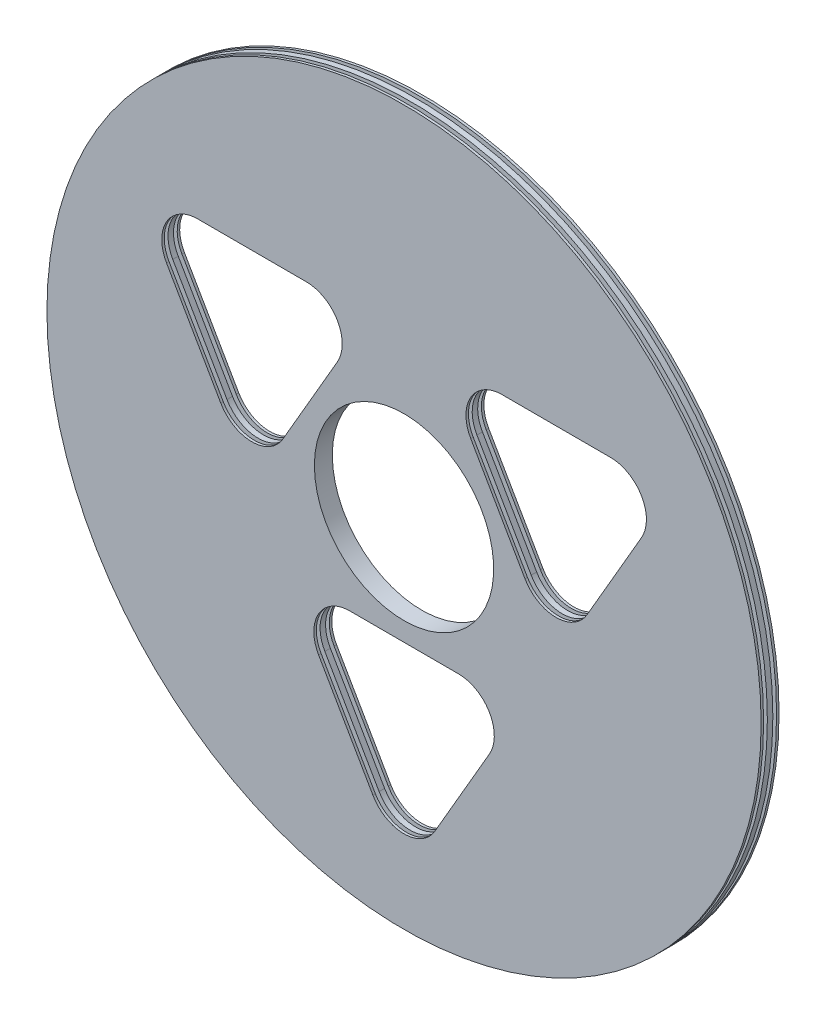
from build123d import *

# Parameters (mm, degrees)
SKETCH_1_R          = 199.1381229
EXTRUDE_1_DEPTH     = 10
SKETCH_2_R          = 50
CUT_EXTRUDE_1_DEPTH = 10
SKETCH_4_W          = 2.080900767
SKETCH_4_H          = 145.70816296


with BuildPart() as part:
    # Эскиз1 → Бобышка-Вытянуть1 (new body)
    with BuildSketch(Plane.XY):
        Circle(SKETCH_1_R)
    extrude(amount=EXTRUDE_1_DEPTH)

    # Эскиз2 → Вырез-Вытянуть1 (cut)
    with BuildSketch(Plane(origin=(0, 0, 0), x_dir=(-1, 0, 0), z_dir=(0, 0, -1))):
        Circle(SKETCH_2_R)
        with BuildLine():
            Line((-132.460540699, 56.403298942), (-102.076076874, 3.945846105))
            ThreePointArc((-102.076076874, 3.945846105), (-84.74156592, -6.029860886), (-67.435094768, 3.994412468))
            Line((-67.435094768, 3.994412468), (-37.197839906, 56.536856438))
            ThreePointArc((-37.197839906, 56.536856438), (-37.225879708, 76.536836783), (-54.560390663, 86.512543774))
            Line((-54.560390663, 86.512543774), (-115.182109349, 86.427552639))
            ThreePointArc((-115.182109349, 86.427552639), (-132.488580502, 76.403279286), (-132.460540699, 56.403298942))
        make_face()
        with BuildLine():
            Line((17.383580609, -142.915842715), (47.620835471, -90.373398744))
            ThreePointArc((47.620835471, -90.373398744), (47.592795668, -70.3734184), (30.258284714, -60.397711409))
            Line((30.258284714, -60.397711409), (-30.363433973, -60.482702544))
            ThreePointArc((-30.363433973, -60.482702544), (-47.669905125, -70.506975897), (-47.641865322, -90.506956241))
            Line((-47.641865322, -90.506956241), (-17.257401498, -142.964409078))
            ThreePointArc((-17.257401498, -142.964409078), (0.077109457, -152.940116069), (17.383580609, -142.915842715))
        make_face()
        with BuildLine():
            Line((115.07696009, 86.512543774), (54.455241404, 86.427552639))
            ThreePointArc((54.455241404, 86.427552639), (37.148770252, 76.403279286), (37.176810054, 56.403298942))
            Line((37.176810054, 56.403298942), (67.561273879, 3.945846105))
            ThreePointArc((67.561273879, 3.945846105), (84.895784833, -6.029860886), (102.202255985, 3.994412468))
            Line((102.202255985, 3.994412468), (132.439510847, 56.536856438))
            ThreePointArc((132.439510847, 56.536856438), (132.411471045, 76.536836783), (115.07696009, 86.512543774))
        make_face()
    extrude(amount=-CUT_EXTRUDE_1_DEPTH, mode=Mode.SUBTRACT)

    # Эскиз4 → Вырез-Повернуть1 (revolve, cut)
    with BuildSketch(Plane(origin=(0, 0, 0), x_dir=(0, 0, -1), z_dir=(1, 0, 0))):
        with Locations((-7.572959809, 126.369713558)):
            Rectangle(SKETCH_4_W, SKETCH_4_H)
        with Locations((-2.427040192, 126.369713558)):
            Rectangle(SKETCH_4_W, SKETCH_4_H)
    revolve(axis=Axis((0, 0, 0.50000655), (0, 0, 1)), mode=Mode.SUBTRACT)


solid = part.part
